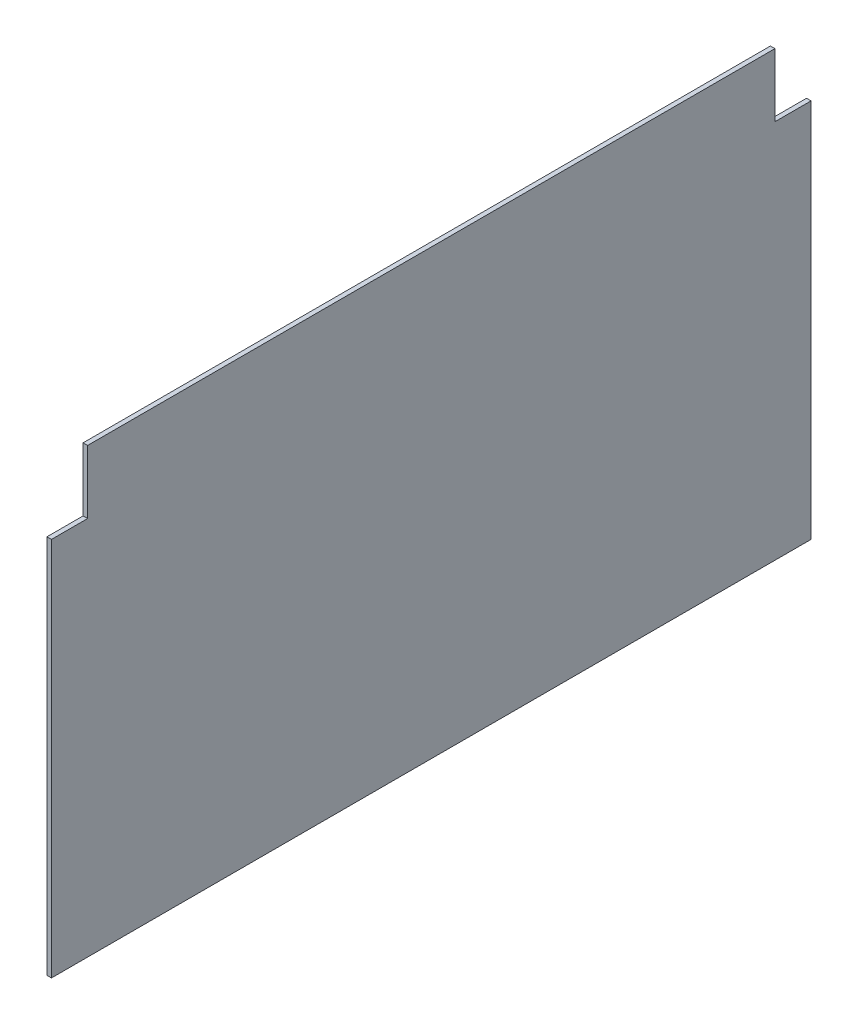
from build123d import *

# Parameters (mm, degrees)
BOSS_EXTRUDE1_DEPTH = 6.35


with BuildPart() as part:
    # Sketch1 → Boss-Extrude1 (new body)
    with BuildSketch(Plane(origin=(0, 0, 0), x_dir=(0, 0, -1), z_dir=(1, 0, 0))):
        Polygon((1016, 533.4), (1066.8, 533.4), (1066.8, 0), (0, 0), (0, 533.4), (50.8, 533.4), (50.8, 622.3), (1016, 622.3), align=None)
    extrude(amount=BOSS_EXTRUDE1_DEPTH)


solid = part.part
